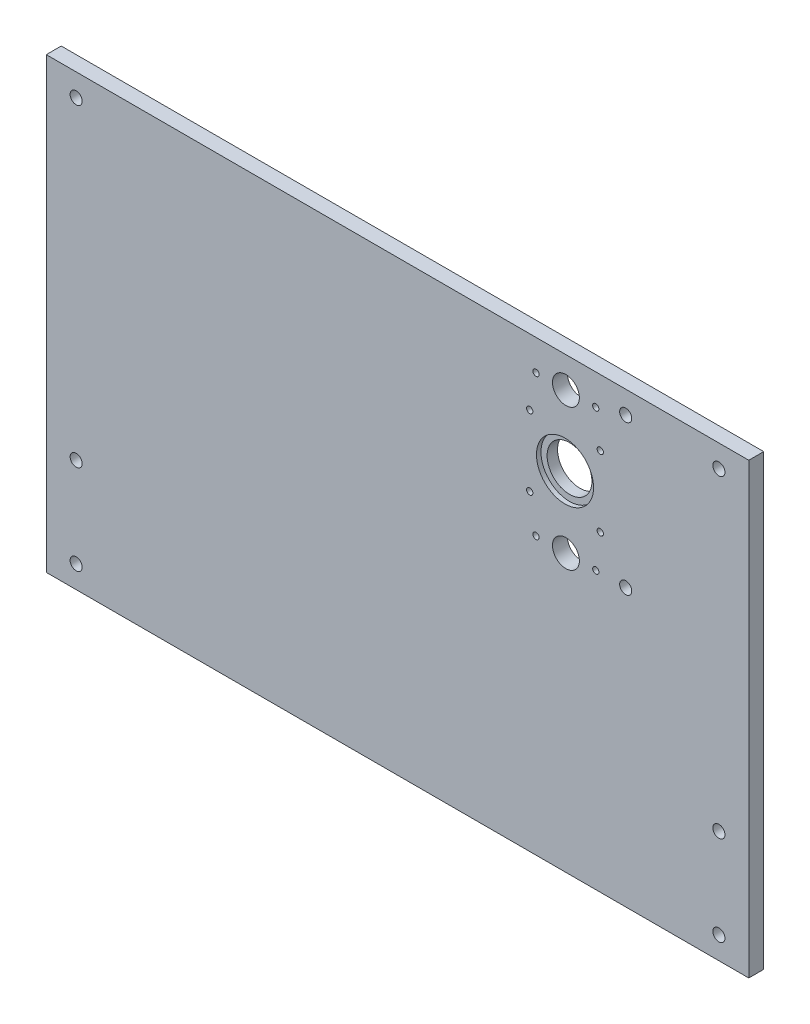
from build123d import *

# Parameters (mm, degrees)
SKETCH2_W           = 470
SKETCH2_H           = 300
BOSS_EXTRUDE1_DEPTH = 5
SKETCH3_R           = 4.05
CUT_EXTRUDE1_DEPTH  = 10
SKETCH4_R           = 9
SKETCH4_R_2         = 2.1
CUT_EXTRUDE2_DEPTH  = 11
SKETCH5_R           = 4.05
CUT_EXTRUDE3_DEPTH  = 11
SKETCH7_R           = 19.1
CUT_EXTRUDE5_DEPTH  = 3
SKETCH8_R           = 15
CUT_EXTRUDE6_DEPTH  = 8
SKETCH9_R           = 2.1
CUT_EXTRUDE7_DEPTH  = 11


with BuildPart() as part:
    # Sketch2 → Boss-Extrude1 (new body, symmetric)
    with BuildSketch(Plane.XY):
        Rectangle(SKETCH2_W, SKETCH2_H)
    extrude(amount=BOSS_EXTRUDE1_DEPTH, both=True)

    # Sketch3 → Cut-Extrude1 (cut)
    with BuildSketch(Plane.XY.offset(5)):
        with Locations((-215, -75)):
            Circle(SKETCH3_R)
        with Locations((-215, -135)):
            Circle(SKETCH3_R)
        with Locations((215, -75)):
            Circle(SKETCH3_R)
        with Locations((215, -135)):
            Circle(SKETCH3_R)
        with Locations((-215, 135)):
            Circle(SKETCH3_R)
        with Locations((215, 135)):
            Circle(SKETCH3_R)
    extrude(amount=-CUT_EXTRUDE1_DEPTH, mode=Mode.SUBTRACT)

    # Sketch4 → Cut-Extrude2 (cut, through all)
    with BuildSketch(Plane.XY.offset(5)):
        with Locations((112.65, 129.5)):
            Circle(SKETCH4_R)
        with Locations((112.65, 35)):
            Circle(SKETCH4_R)
        with Locations((92.65, 129.5)):
            Circle(SKETCH4_R_2)
        with Locations((132.65, 129.5)):
            Circle(SKETCH4_R_2)
        with Locations((132.65, 35)):
            Circle(SKETCH4_R_2)
        with Locations((92.65, 35)):
            Circle(SKETCH4_R_2)
    extrude(amount=-CUT_EXTRUDE2_DEPTH, mode=Mode.SUBTRACT)

    # Sketch5 → Cut-Extrude3 (cut, through all)
    with BuildSketch(Plane.XY.offset(5)):
        with Locations((152.65, 135)):
            Circle(SKETCH5_R)
        with Locations((152.65, 35)):
            Circle(SKETCH5_R)
    extrude(amount=-CUT_EXTRUDE3_DEPTH, mode=Mode.SUBTRACT)

    # Sketch7 → Cut-Extrude5 (cut)
    with BuildSketch(Plane.XY.offset(5)):
        with Locations((112.05, 82.25)):
            Circle(SKETCH7_R)
    extrude(amount=-CUT_EXTRUDE5_DEPTH, mode=Mode.SUBTRACT)

    # Sketch8 → Cut-Extrude6 (cut, through all)
    with BuildSketch(Plane.XY.offset(2)):
        with Locations((112.05, 82.25)):
            Circle(SKETCH8_R)
    extrude(amount=-CUT_EXTRUDE6_DEPTH, mode=Mode.SUBTRACT)

    # Sketch9 → Cut-Extrude7 (cut, through all)
    with BuildSketch(Plane.XY.offset(5)):
        with Locations((88.45, 105.85)):
            Circle(SKETCH9_R)
        with Locations((135.65, 105.85)):
            Circle(SKETCH9_R)
        with Locations((135.65, 58.65)):
            Circle(SKETCH9_R)
        with Locations((88.45, 58.65)):
            Circle(SKETCH9_R)
    extrude(amount=-CUT_EXTRUDE7_DEPTH, mode=Mode.SUBTRACT)


solid = part.part
